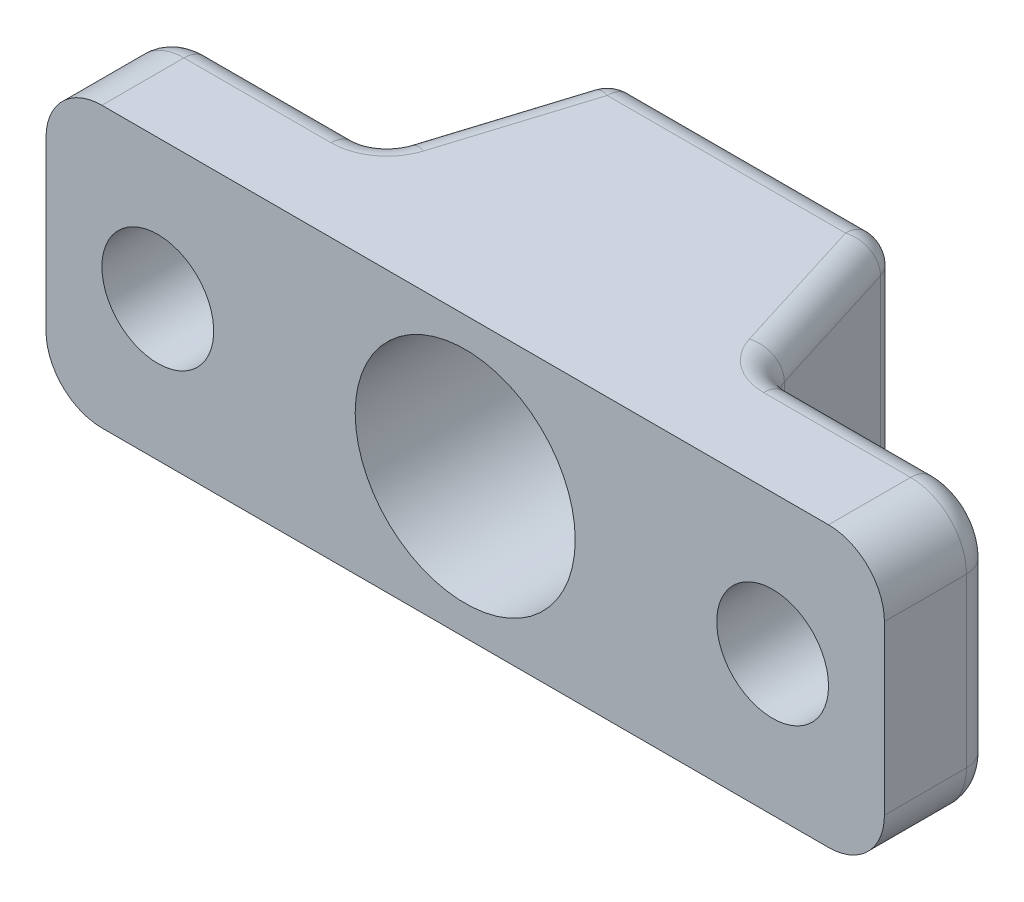
from build123d import *

# Parameters (mm, degrees)
BOSS_EXTRUDE1_DEPTH = 12.7
SKETCH2_R           = 5
CUT_EXTRUDE1_DEPTH  = 14.137790614
SKETCH3_R           = 2.54
CUT_EXTRUDE2_DEPTH  = 6
FILLET1_R           = 2.54
FILLET2_R           = 1.27


with BuildPart() as part:
    # Sketch1 → Boss-Extrude1 (new body)
    with BuildSketch(Plane(origin=(0, 0, 0), x_dir=(1, 0, 0), z_dir=(0, 1, 0))):
        Polygon((19.05, 0), (-19.05, 0), (-19.05, 5), (-8.89, 5), (-6.35, 13.137790614), (6.35, 13.137790614), (8.89, 5), (19.05, 5), align=None)
    extrude(amount=BOSS_EXTRUDE1_DEPTH)

    # Sketch2 → Cut-Extrude1 (cut, through all)
    with BuildSketch(Plane(origin=(0, 0, -13.137790614), x_dir=(-1, 0, 0), z_dir=(0, 0, -1))):
        with Locations((0, 6.35)):
            Circle(SKETCH2_R)
    extrude(amount=-CUT_EXTRUDE1_DEPTH, mode=Mode.SUBTRACT)

    # Sketch3 → Cut-Extrude2 (cut, through all)
    with BuildSketch(Plane(origin=(0, 0, -5), x_dir=(-1, 0, 0), z_dir=(0, 0, -1))):
        with Locations((13.97, 6.35)):
            Circle(SKETCH3_R)
        with Locations((-13.97, 6.35)):
            Circle(SKETCH3_R)
    extrude(amount=-CUT_EXTRUDE2_DEPTH, mode=Mode.SUBTRACT)

    # Fillet1
    fillet1_edges = [part.edges().sort_by_distance(p)[0] for p in [
        (19.05, 12.7, -2.5),
        (-19.05, 0, -2.5),
        (-19.05, 12.7, -2.5),
        (19.05, 0, -2.5),
    ]]
    fillet(fillet1_edges, radius=FILLET1_R)

    # Fillet2
    fillet2_edges = [part.edges().sort_by_distance(p)[0] for p in [
        (-8.89, 6.35, -5),
        (-6.35, 6.35, -13.137790614),
        (6.35, 6.35, -13.137790614),
        (8.89, 6.35, -5),
        (7.62, 12.7, -9.068895307),
        (0, 12.7, -13.137790614),
        (-7.62, 12.7, -9.068895307),
        (-12.7, 12.7, -5),
        (-19.05, 6.35, -5),
        (12.7, 0, -5),
        (-18.306051224, 11.956051224, -5),
        (-18.306051224, 0.743948776, -5),
        (19.05, 6.35, -5),
        (12.7, 12.7, -5),
        (18.306051224, 11.956051224, -5),
        (18.306051224, 0.743948776, -5),
        (-12.7, 0, -5),
        (-7.62, 0, -9.068895307),
        (0, 0, -13.137790614),
        (7.62, 0, -9.068895307),
    ]]
    fillet(fillet2_edges, radius=FILLET2_R)


solid = part.part
